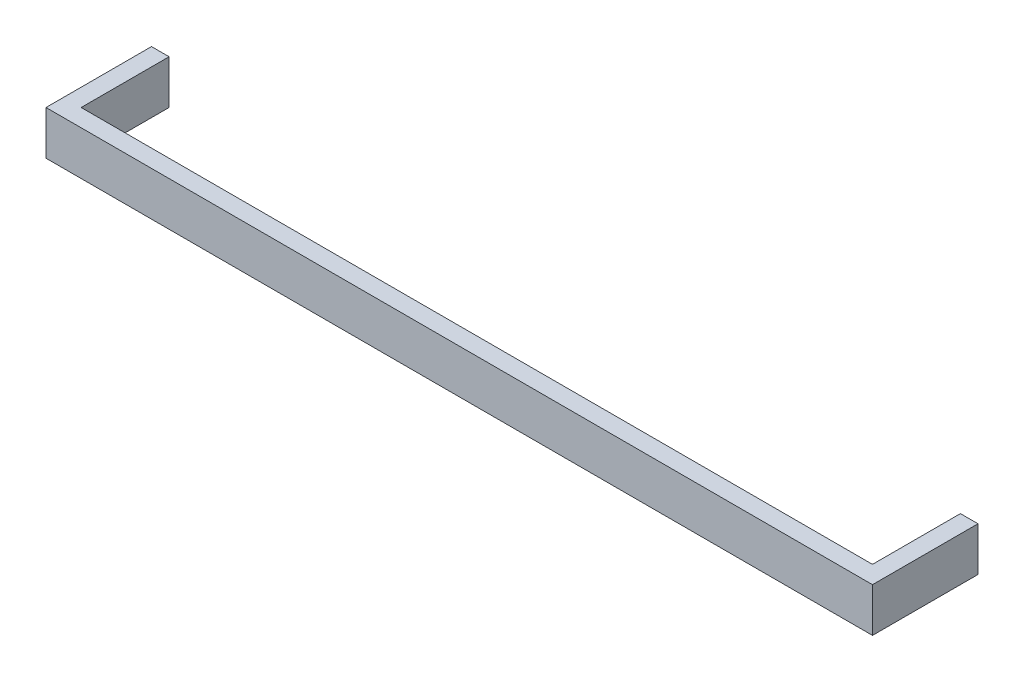
from build123d import *

# Parameters (mm, degrees)
BOSS_EXTRUDE1_DEPTH = 5


with BuildPart() as part:
    # Sketch1 → Boss-Extrude1 (new body)
    with BuildSketch(Plane(origin=(0, 0, 0), x_dir=(1, 0, 0), z_dir=(0, 1, 0))):
        Polygon((0, 0), (90, 0), (90, 10), (92, 10), (92, -2), (-2, -2), (-2, 10), (0, 10), align=None)
    extrude(amount=BOSS_EXTRUDE1_DEPTH)


solid = part.part
